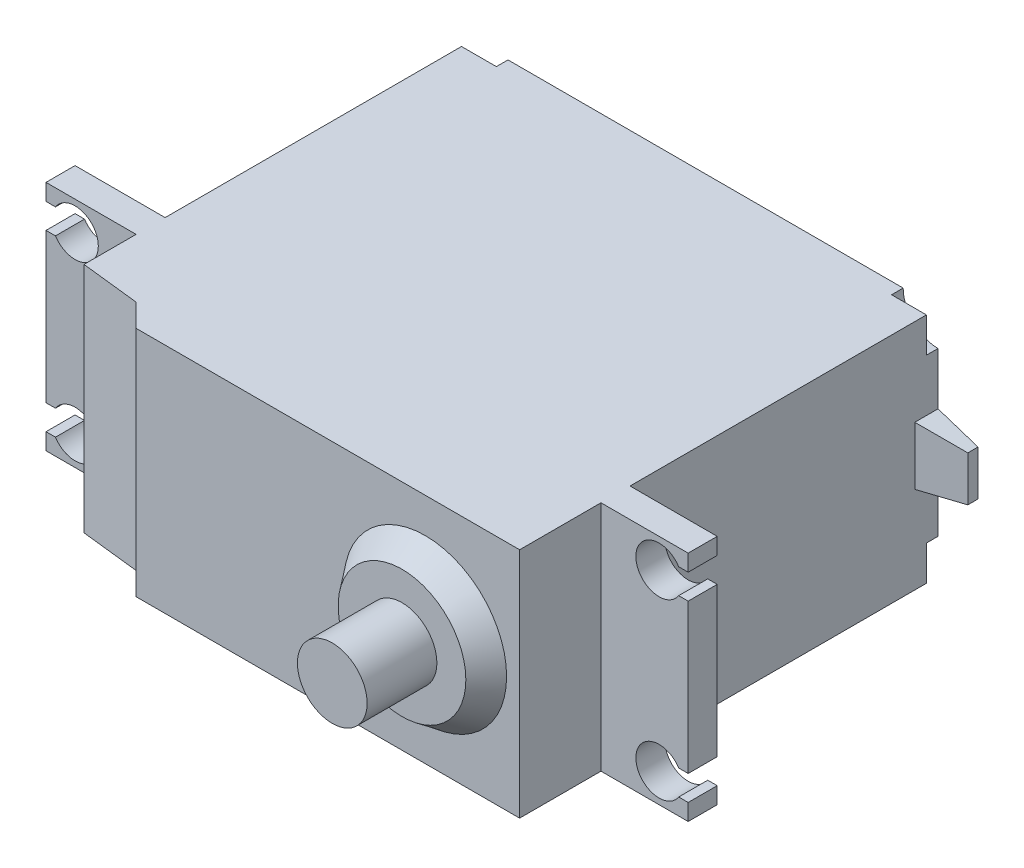
from build123d import *

# Parameters (mm, degrees)
SKETCH2_W           = 40
SKETCH2_H           = 20
EXTRUDE1_DEPTH      = 36
SKETCH3_W           = 2.5
SKETCH3_H           = 20
EXTRUDE2_DEPTH      = 7.75
EXTRUDE2_DEPTH_BACK = 47.5
EXTRUDE3_DEPTH      = 1
SKETCH5_W           = 2
SKETCH5_H           = 5
EXTRUDE4_DEPTH      = 4
EXTRUDE4_TAPER      = 8
EXTRUDE7_DEPTH      = 24
EXTRUDE7_DEPTH_BACK = 12
SKETCH8_R           = 7
EXTRUDE8_DEPTH      = 2
EXTRUDE8_TAPER      = 37
EXTRUDE9_DEPTH      = 15
EXTRUDE9_DEPTH_BACK = 24
SKETCH10_R          = 3
EXTRUDE10_DEPTH     = 6


with BuildPart() as part:
    # Sketch2 → Extrude1 (new body)
    with BuildSketch(Plane.XY):
        with Locations((20, 10)):
            Rectangle(SKETCH2_W, SKETCH2_H)
    extrude(amount=EXTRUDE1_DEPTH)

    # Sketch3 → Extrude2 (add, two sides)
    with BuildSketch(Plane.ZY) as extrude2_sk:
        with Locations((27.75, 10)):
            Rectangle(SKETCH3_W, SKETCH3_H)
    extrude(amount=EXTRUDE2_DEPTH)
    extrude(extrude2_sk.sketch, amount=-EXTRUDE2_DEPTH_BACK)

    # Sketch4 → Extrude3 (cut)
    with BuildSketch(Plane(origin=(0, 0, 0), x_dir=(-1, 0, 0), z_dir=(0, 0, -1))):
        with BuildLine():
            Line((-37, 20), (-40, 20))
            Line((-40, 20), (-40, 17))
            ThreePointArc((-40, 17), (-37.878679656, 17.878679656), (-37, 20))
        make_face()
        with BuildLine():
            Line((-40, 3), (-40, 0))
            Line((-40, 0), (-37, 0))
            ThreePointArc((-37, 0), (-37.878679656, 2.121320344), (-40, 3))
        make_face()
        with BuildLine():
            Line((0, 3), (0, 0))
            Line((0, 0), (-3, 0))
            ThreePointArc((-3, 0), (-2.121320344, 2.121320344), (0, 3))
        make_face()
        with BuildLine():
            Line((0, 17), (0, 20))
            Line((0, 20), (-3, 20))
            ThreePointArc((-3, 20), (-2.121320344, 17.878679656), (0, 17))
        make_face()
    extrude(amount=-EXTRUDE3_DEPTH, mode=Mode.SUBTRACT)

    # Sketch6 → Extrude7 (cut, two sides)
    with BuildSketch(Plane.XY.offset(29)) as extrude7_sk:
        with BuildLine():
            Line((-6.93456787, 3.578068222), (-7.75, 3.578068222))
            Line((-7.75, 3.578068222), (-7.75, 1.421931778))
            Line((-7.75, 1.421931778), (-6.93456787, 1.421931778))
            ThreePointArc((-6.93456787, 1.421931778), (-3.25, 2.5), (-6.93456787, 3.578068222))
        make_face()
        with BuildLine():
            Line((46.68456787, 18.578068222), (47.5, 18.578068222))
            Line((47.5, 18.578068222), (47.5, 16.421931778))
            Line((47.5, 16.421931778), (46.68456787, 16.421931778))
            ThreePointArc((46.68456787, 16.421931778), (43, 17.5), (46.68456787, 18.578068222))
        make_face()
        with BuildLine():
            ThreePointArc((46.68456787, 1.421931778), (43, 2.5), (46.68456787, 3.578068222))
            Line((46.68456787, 3.578068222), (47.5, 3.578068222))
            Line((47.5, 3.578068222), (47.5, 1.421931778))
            Line((47.5, 1.421931778), (46.68456787, 1.421931778))
        make_face()
        with BuildLine():
            ThreePointArc((-6.93456787, 16.421931778), (-3.25, 17.5), (-6.93456787, 18.578068222))
            Line((-6.93456787, 18.578068222), (-7.75, 18.578068222))
            Line((-7.75, 18.578068222), (-7.75, 16.421931778))
            Line((-7.75, 16.421931778), (-6.93456787, 16.421931778))
        make_face()
    extrude(amount=EXTRUDE7_DEPTH, mode=Mode.SUBTRACT)
    extrude(extrude7_sk.sketch, amount=-EXTRUDE7_DEPTH_BACK, mode=Mode.SUBTRACT)

    # Sketch8 → Extrude8 (add)
    with BuildSketch(Plane.XY.offset(36)):
        with Locations((31.880492546, 10)):
            Circle(SKETCH8_R)
    extrude(amount=EXTRUDE8_DEPTH, taper=EXTRUDE8_TAPER)

    # Sketch9 → Extrude9 (cut, two sides)
    with BuildSketch(Plane.XZ) as extrude9_sk:
        Polygon((7, 36), (5.046113412, 34.046113412), (0, 33.479218226), (0, 34.046113412), (0, 36), align=None)
    extrude(amount=EXTRUDE9_DEPTH, mode=Mode.SUBTRACT)
    extrude(extrude9_sk.sketch, amount=-EXTRUDE9_DEPTH_BACK, mode=Mode.SUBTRACT)

    # Sketch10 → Extrude10 (add)
    with BuildSketch(Plane.XY.offset(38)):
        with Locations((31.880492546, 10)):
            Circle(SKETCH10_R)
    extrude(amount=EXTRUDE10_DEPTH)


with BuildPart() as body_2:
    # Sketch5 → Extrude4 (new body)
    with BuildSketch(Plane(origin=(40, 0, 0), x_dir=(0, 0, -1), z_dir=(1, 0, 0))):
        with Locations((-1, 10)):
            Rectangle(SKETCH5_W, SKETCH5_H)
    extrude(amount=EXTRUDE4_DEPTH, taper=EXTRUDE4_TAPER)


solid = Compound([part.part, body_2.part])
